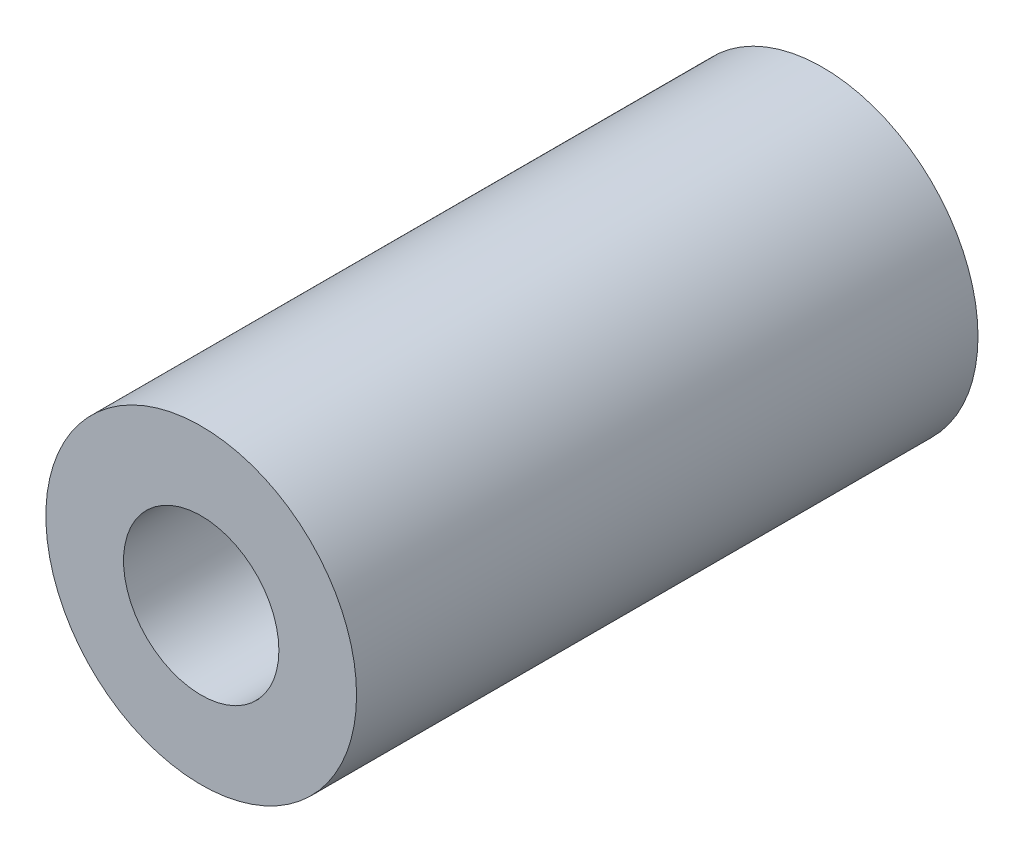
from build123d import *

# Parameters (mm, degrees)
SKETCH1_R           = 12.7
SKETCH1_R_2         = 6.35
BOSS_EXTRUDE1_DEPTH = 50.8


with BuildPart() as part:
    # Sketch1 → Boss-Extrude1 (new body)
    with BuildSketch(Plane.XY):
        Circle(SKETCH1_R)
        Circle(SKETCH1_R_2, mode=Mode.SUBTRACT)
    extrude(amount=BOSS_EXTRUDE1_DEPTH)


solid = part.part
